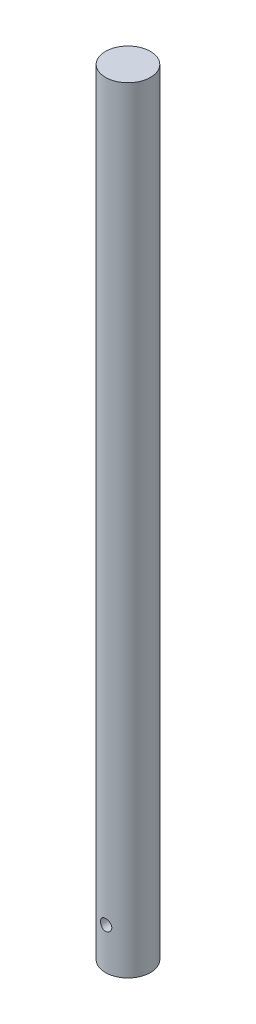
from build123d import *

# Parameters (mm, degrees)
CROQUIS4_R                 = 19.05
SALIENTE_EXTRUIR2_DEPTH    = 656.12
CROQUIS5_R                 = 4.765
CORTAR_EXTRUIR2_DEPTH      = 20.05
CORTAR_EXTRUIR2_DEPTH_BACK = 20.05


with BuildPart() as part:
    # Croquis4 → Saliente-Extruir2 (new body)
    with BuildSketch(Plane(origin=(0, 0, 0), x_dir=(1, 0, 0), z_dir=(0, 1, 0))):
        Circle(CROQUIS4_R)
    extrude(amount=SALIENTE_EXTRUIR2_DEPTH)

    # Croquis5 → Cortar-Extruir2 (cut, two sides)
    with BuildSketch(Plane.XY) as cortar_extruir2_sk:
        with Locations((0, 35)):
            Circle(CROQUIS5_R)
    extrude(amount=CORTAR_EXTRUIR2_DEPTH, mode=Mode.SUBTRACT)
    extrude(cortar_extruir2_sk.sketch, amount=-CORTAR_EXTRUIR2_DEPTH_BACK, mode=Mode.SUBTRACT)


solid = part.part
